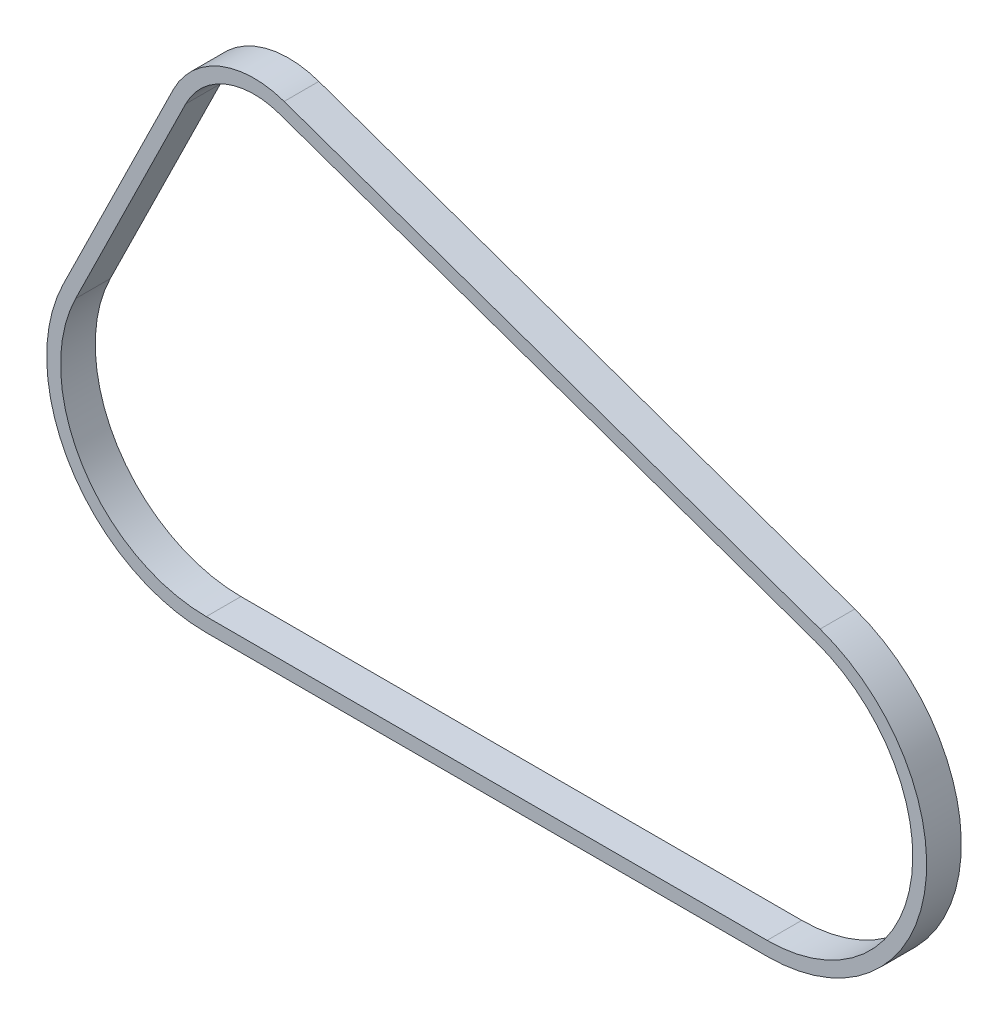
from build123d import *

# Parameters (mm, degrees)
EXTRUDE_THIN1_DEPTH      = 7.5
EXTRUDE_THIN1_DEPTH_BACK = 7.5


with BuildPart() as part:
    # Sketch2 → Extrude-Thin1 (new, two sides)
    with BuildSketch(Plane.XY) as extrude_thin1_sk:
        with BuildLine():
            Line((244.758005067, -44.924616728), (12.965481959, 36.781738371))
            ThreePointArc((12.965481959, 36.781738371), (-14.726749562, 36.112641102), (-34.989695357, 17.225597779))
            Line((-34.989695357, 17.225597779), (-82.619966134, -79.523942391))
            ThreePointArc((-82.619966134, -79.523942391), (-79.297745807, -146.456494792), (-20.715120503, -179))
            Line((-20.715120503, -179), (221.819075448, -179))
            ThreePointArc((221.819075448, -179), (289.830844451, -121.636119505), (244.758005067, -44.924616728))
        make_face()
        with BuildLine():
            Line((242.763315535, -50.583345709), (10.970792426, 31.123009391))
            ThreePointArc((10.970792426, 31.123009391), (-12.461095783, 30.556850163), (-29.606665302, 14.575505813))
            Line((-29.606665302, 14.575505813), (-77.236936079, -82.174034357))
            ThreePointArc((-77.236936079, -82.174034357), (-74.203604476, -143.28636481), (-20.715120503, -173))
            Line((-20.715120503, -173), (221.819075448, -173))
            ThreePointArc((221.819075448, -173), (283.916777581, -120.624283026), (242.763315535, -50.583345709))
        make_face(mode=Mode.SUBTRACT)
    extrude(amount=EXTRUDE_THIN1_DEPTH)
    extrude(extrude_thin1_sk.sketch, amount=-EXTRUDE_THIN1_DEPTH_BACK)


solid = part.part
